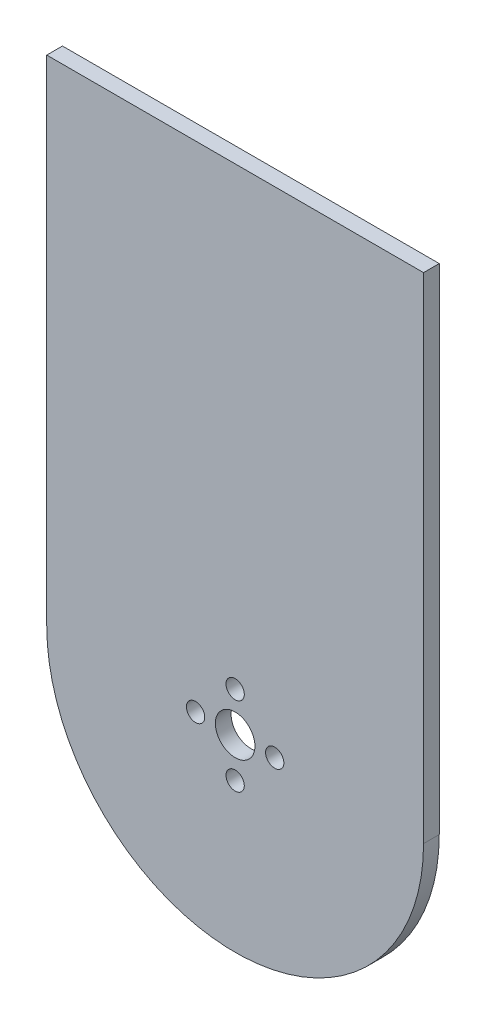
from build123d import *

# Parameters (mm, degrees)
SKETCH1_R           = 4
SKETCH1_R_2         = 1.85
BOSS_EXTRUDE1_DEPTH = 3.175


with BuildPart() as part:
    # Sketch1 → Boss-Extrude1 (new body)
    with BuildSketch(Plane.XY):
        with BuildLine():
            Line((-38.1, 100), (38.1, 100))
            Line((38.1, 100), (38.1, 0))
            ThreePointArc((38.1, 0), (0, -38.1), (-38.1, 0))
            Line((-38.1, 0), (-38.1, 100))
        make_face()
        Circle(SKETCH1_R, mode=Mode.SUBTRACT)
        with Locations((-8, 0)):
            Circle(SKETCH1_R_2, mode=Mode.SUBTRACT)
        with Locations((0, -8)):
            Circle(SKETCH1_R_2, mode=Mode.SUBTRACT)
        with Locations((0, 8)):
            Circle(SKETCH1_R_2, mode=Mode.SUBTRACT)
        with Locations((8, 0)):
            Circle(SKETCH1_R_2, mode=Mode.SUBTRACT)
    extrude(amount=BOSS_EXTRUDE1_DEPTH)


solid = part.part
